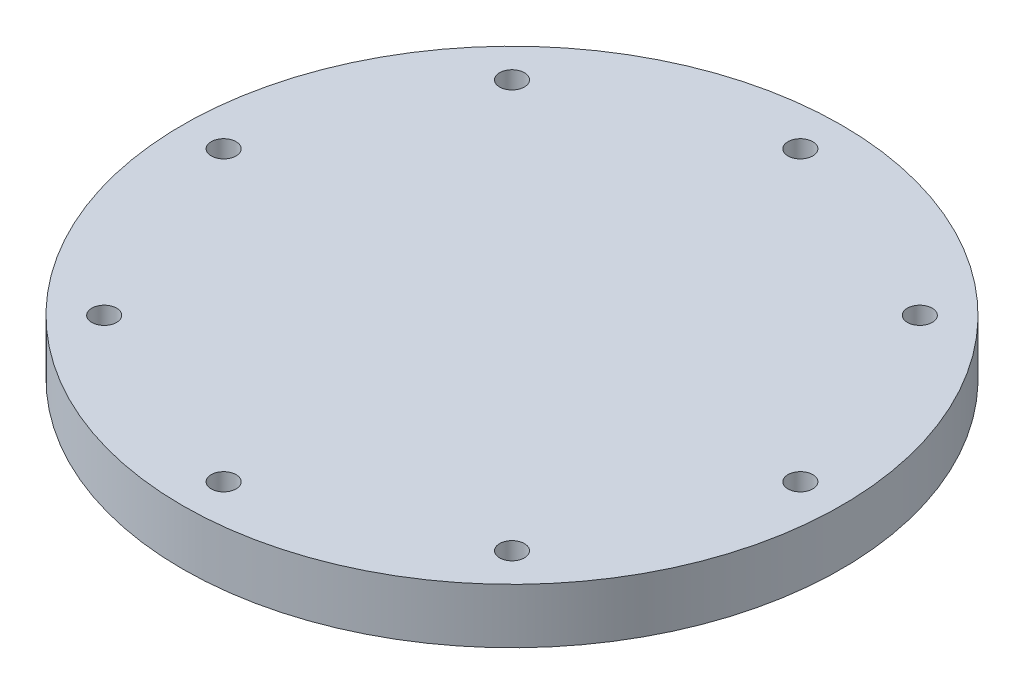
from build123d import *

# Parameters (mm, degrees)
SKETCH1_R                                      = 38.1
BOSS_EXTRUDE1_DEPTH                            = 6.35
CBORE_FOR_4_BUTTON_HEAD_CAP_SCREW1_D           = 2.8702
CBORE_FOR_4_BUTTON_HEAD_CAP_SCREW1_CBORE_D     = 4.826
CBORE_FOR_4_BUTTON_HEAD_CAP_SCREW1_CBORE_DEPTH = 3.175
CIRPATTERN1_COUNT                              = 8


with BuildPart() as part:
    # Sketch1 → Boss-Extrude1 (new body)
    with BuildSketch(Plane(origin=(0, 0, 0), x_dir=(1, 0, 0), z_dir=(0, 1, 0))):
        Circle(SKETCH1_R)
    extrude(amount=BOSS_EXTRUDE1_DEPTH)

    # CBORE for #4 Button Head Cap Screw1 (through all)
    with Locations(Plane(origin=(0, 0, 0), x_dir=(-1, 0, 0), z_dir=(0, -1, 0))):
        with Locations((0, -33.3375)):
            cbore_for_4_button_head_cap_screw1 = CounterBoreHole(CBORE_FOR_4_BUTTON_HEAD_CAP_SCREW1_D / 2, CBORE_FOR_4_BUTTON_HEAD_CAP_SCREW1_CBORE_D / 2, CBORE_FOR_4_BUTTON_HEAD_CAP_SCREW1_CBORE_DEPTH)

    # CirPattern1: CBORE for #4 Button Head Cap Screw1 ×8 about axis
    cirpattern1_axis = Axis((0, 0, 0), (0, 1, 0))
    for i in range(1, CIRPATTERN1_COUNT):
        add(cbore_for_4_button_head_cap_screw1.rotate(cirpattern1_axis, i * 360 / CIRPATTERN1_COUNT), mode=Mode.SUBTRACT)


solid = part.part
